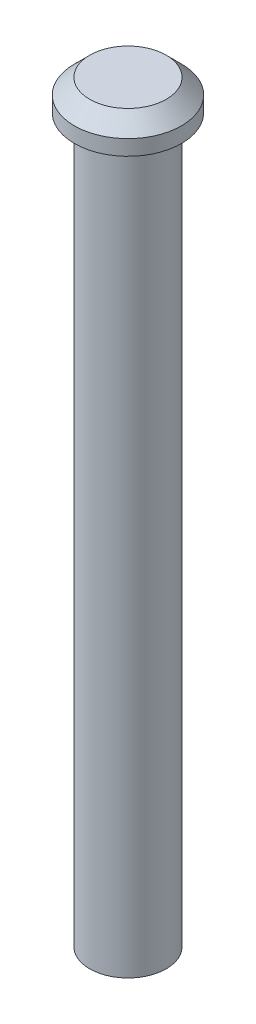
from build123d import *

# Parameters (mm, degrees)
SKETCH1_R           = 2.5
BOSS_EXTRUDE1_DEPTH = 47.2
SKETCH2_R           = 3.5
BOSS_EXTRUDE2_DEPTH = 2
CHAMFER1_SIZE       = 1
SKETCH3_R           = 1.5
CUT_EXTRUDE1_DEPTH  = 5


with BuildPart() as part:
    # Sketch1 → Boss-Extrude1 (new body)
    with BuildSketch(Plane(origin=(0, 0, 0), x_dir=(1, 0, 0), z_dir=(0, 1, 0))):
        Circle(SKETCH1_R)
    extrude(amount=BOSS_EXTRUDE1_DEPTH)

    # Sketch2 → Boss-Extrude2 (add)
    with BuildSketch(Plane(origin=(0, 47.2, 0), x_dir=(1, 0, 0), z_dir=(0, 1, 0))):
        Circle(SKETCH2_R)
    extrude(amount=BOSS_EXTRUDE2_DEPTH)

    # Chamfer1
    chamfer1_edges = [part.edges().sort_by_distance(p)[0] for p in [
        (-3.5, 49.2, 0),
    ]]
    chamfer(chamfer1_edges, length=CHAMFER1_SIZE)

    # Sketch3 → Cut-Extrude1 (cut)
    with BuildSketch(Plane.XZ):
        Circle(SKETCH3_R)
    extrude(amount=-CUT_EXTRUDE1_DEPTH, mode=Mode.SUBTRACT)


solid = part.part
